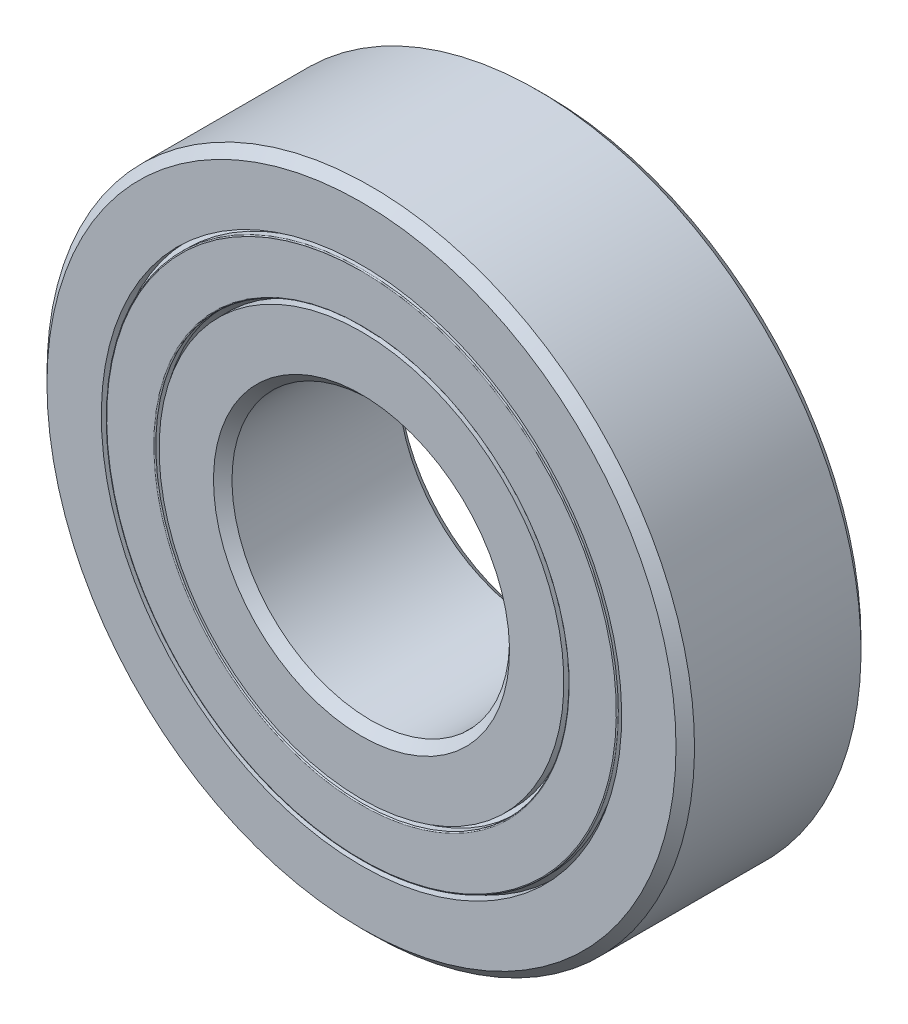
from build123d import *

# Parameters (mm, degrees)
CIRPATTERN1_COUNT   = 8
SKETCH7_R           = 10.625
SKETCH7_R_2         = 10
BOSS_EXTRUDE1_DEPTH = 0.666666667
FILLET1_R           = 0.044444444
FILLET2_R           = 0.044444444


with BuildPart() as part:
    # Sketch3 → Revolve1 (revolve)
    with BuildSketch(Plane(origin=(0, 0, 0), x_dir=(0, 0, -1), z_dir=(1, 0, 0))):
        with BuildLine():
            Line((3.6, 14), (4, 13.6))
            Line((4, 13.6), (4, 11.25))
            Line((4, 11.25), (1.777777778, 11.25))
            ThreePointArc((1.777777778, 11.25), (0, 12.173244999), (-1.777777778, 11.25))
            Line((-1.777777778, 11.25), (-4, 11.25))
            Line((-4, 11.25), (-4, 13.6))
            Line((-4, 13.6), (-3.6, 14))
            Line((-3.6, 14), (3.6, 14))
        make_face()
    revolve(axis=Axis((0, 0, 4), (0, 0, -1)))


with BuildPart() as body_2:
    # Sketch4 → Revolve2 (revolve)
    with BuildSketch(Plane(origin=(0, 0, 0), x_dir=(0, 0, -1), z_dir=(1, 0, 0))):
        with BuildLine():
            Line((-3.6, 6), (-4, 6.4))
            Line((-4, 6.4), (-4, 8.75))
            Line((-4, 8.75), (-1.777777778, 8.75))
            ThreePointArc((-1.777777778, 8.75), (0, 7.826755001), (1.777777778, 8.75))
            Line((1.777777778, 8.75), (4, 8.75))
            Line((4, 8.75), (4, 6.4))
            Line((4, 6.4), (3.6, 6))
            Line((3.6, 6), (-3.6, 6))
        make_face()
    revolve(axis=Axis((0, 0, 4), (0, 0, -1)))


with BuildPart() as body_3:
    # Sketch5 → Revolve3 (revolve)
    with BuildSketch(Plane(origin=(0, 0, 0), x_dir=(0, 0, -1), z_dir=(1, 0, 0))):
        with BuildLine():
            Line((-2.173244999, 10), (2.173244999, 10))
            ThreePointArc((2.173244999, 10), (0, 12.173244999), (-2.173244999, 10))
        make_face()
    revolve(axis=Axis((0, 10, 2.173244999), (0, 0, -1)))


with BuildPart() as body_4:
    # Sketch6 → Revolve4 (revolve)
    with BuildSketch(Plane(origin=(0, 0, 0), x_dir=(0, 0, -1), z_dir=(1, 0, 0))):
        with BuildLine():
            Line((-2.08143432, 10.625), (-2.401195266, 10.625))
            ThreePointArc((-2.401195266, 10.625), (-2.56107574, 10), (-2.401195266, 9.375))
            Line((-2.401195266, 9.375), (-2.08143432, 9.375))
            ThreePointArc((-2.08143432, 9.375), (-2.173244999, 10), (-2.08143432, 10.625))
        make_face()
    revolve(axis=Axis((0, 14, 0), (0, -1, 0)))


with BuildPart() as cirpattern1_1:
    # CirPattern1: pattern copy
    add(body_4.part.rotate(Axis((0, 0, 0), (0, 0, 1)), 1 * 360 / CIRPATTERN1_COUNT))


with BuildPart() as cirpattern1_2:
    # CirPattern1: pattern copy
    add(body_4.part.rotate(Axis((0, 0, 0), (0, 0, 1)), 2 * 360 / CIRPATTERN1_COUNT))


with BuildPart() as cirpattern1_3:
    # CirPattern1: pattern copy
    add(body_4.part.rotate(Axis((0, 0, 0), (0, 0, 1)), 3 * 360 / CIRPATTERN1_COUNT))


with BuildPart() as cirpattern1_4:
    # CirPattern1: pattern copy
    add(body_4.part.rotate(Axis((0, 0, 0), (0, 0, 1)), 4 * 360 / CIRPATTERN1_COUNT))


with BuildPart() as cirpattern1_5:
    # CirPattern1: pattern copy
    add(body_4.part.rotate(Axis((0, 0, 0), (0, 0, 1)), 5 * 360 / CIRPATTERN1_COUNT))


with BuildPart() as cirpattern1_6:
    # CirPattern1: pattern copy
    add(body_4.part.rotate(Axis((0, 0, 0), (0, 0, 1)), 6 * 360 / CIRPATTERN1_COUNT))


with BuildPart() as cirpattern1_7:
    # CirPattern1: pattern copy
    add(body_4.part.rotate(Axis((0, 0, 0), (0, 0, 1)), 7 * 360 / CIRPATTERN1_COUNT))


with BuildPart() as cirpattern1_8:
    # CirPattern1: pattern copy
    add(body_3.part.rotate(Axis((0, 0, 0), (0, 0, 1)), 1 * 360 / CIRPATTERN1_COUNT))


with BuildPart() as cirpattern1_9:
    # CirPattern1: pattern copy
    add(body_3.part.rotate(Axis((0, 0, 0), (0, 0, 1)), 2 * 360 / CIRPATTERN1_COUNT))


with BuildPart() as cirpattern1_10:
    # CirPattern1: pattern copy
    add(body_3.part.rotate(Axis((0, 0, 0), (0, 0, 1)), 3 * 360 / CIRPATTERN1_COUNT))


with BuildPart() as cirpattern1_11:
    # CirPattern1: pattern copy
    add(body_3.part.rotate(Axis((0, 0, 0), (0, 0, 1)), 4 * 360 / CIRPATTERN1_COUNT))


with BuildPart() as cirpattern1_12:
    # CirPattern1: pattern copy
    add(body_3.part.rotate(Axis((0, 0, 0), (0, 0, 1)), 5 * 360 / CIRPATTERN1_COUNT))


with BuildPart() as cirpattern1_13:
    # CirPattern1: pattern copy
    add(body_3.part.rotate(Axis((0, 0, 0), (0, 0, 1)), 6 * 360 / CIRPATTERN1_COUNT))


with BuildPart() as cirpattern1_14:
    # CirPattern1: pattern copy
    add(body_3.part.rotate(Axis((0, 0, 0), (0, 0, 1)), 7 * 360 / CIRPATTERN1_COUNT))


with BuildPart() as body_19:
    # Sketch7 → Boss-Extrude1 (new body, symmetric)
    with BuildSketch(Plane.XY):
        Circle(SKETCH7_R)
        Circle(SKETCH7_R_2, mode=Mode.SUBTRACT)
    extrude(amount=BOSS_EXTRUDE1_DEPTH, both=True)


with BuildPart() as body_20:
    # Sketch8 → Revolve5 (revolve)
    with BuildSketch(Plane(origin=(0, 0, 0), x_dir=(0, 0, -1), z_dir=(1, 0, 0))):
        Polygon((-4, 11.0625), (-3.703703704, 11.0625), (-3.555555556, 11.25), (-3.555555556, 11.0625), (-3.555555556, 8.9375), (-3.555555556, 8.75), (-3.703703704, 8.9375), (-4, 8.9375), align=None)
        Polygon((4, 11.0625), (4, 8.9375), (3.703703704, 8.9375), (3.555555556, 8.75), (3.555555556, 8.9375), (3.555555556, 11.0625), (3.555555556, 11.25), (3.703703704, 11.0625), align=None)
    revolve(axis=Axis((0, 0, 4), (0, 0, -1)))

    # Fillet1
    fillet1_edges = [body_20.edges().sort_by_distance(p)[0] for p in [
        (0, -11.0625, 4),
        (0, -8.9375, 4),
    ]]
    fillet(fillet1_edges, radius=FILLET1_R)

    # Fillet2
    fillet2_edges = [body_20.edges().sort_by_distance(p)[0] for p in [
        (0, -11.0625, -4),
        (0, -8.9375, -4),
    ]]
    fillet(fillet2_edges, radius=FILLET2_R)


solid = Compound([part.part, body_2.part, body_3.part, body_4.part, cirpattern1_1.part, cirpattern1_2.part, cirpattern1_3.part, cirpattern1_4.part, cirpattern1_5.part, cirpattern1_6.part, cirpattern1_7.part, cirpattern1_8.part, cirpattern1_9.part, cirpattern1_10.part, cirpattern1_11.part, cirpattern1_12.part, cirpattern1_13.part, cirpattern1_14.part, body_19.part, body_20.part])
